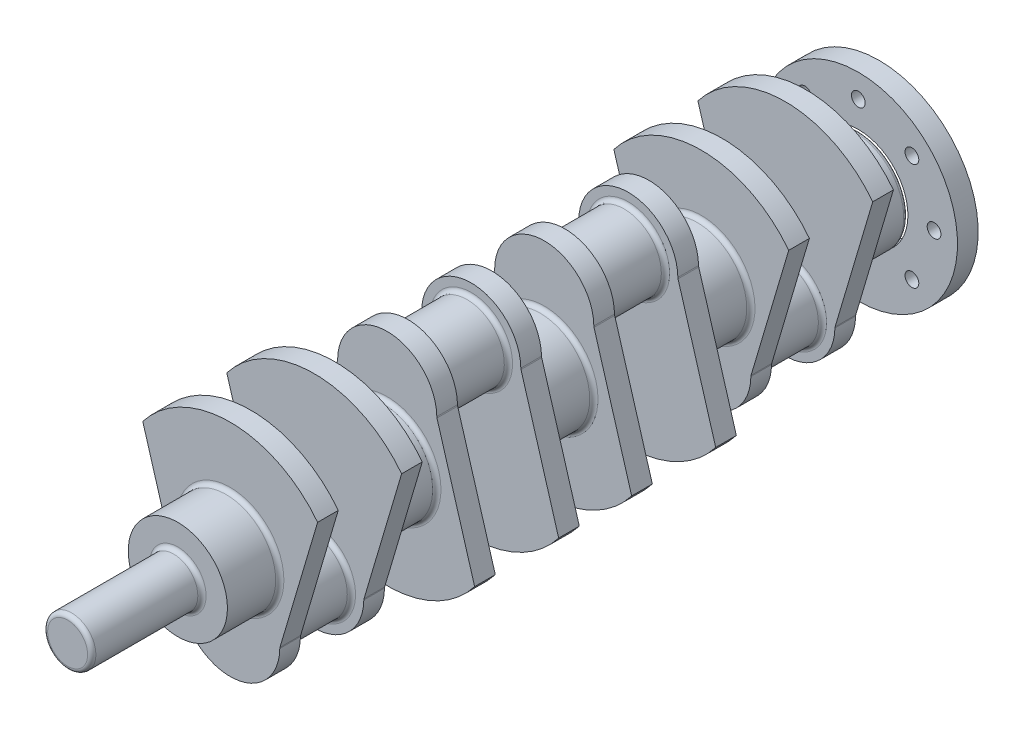
from build123d import *

# Parameters (mm, degrees)
SKETCH1_R             = 36
BOSS_EXTRUDE1_DEPTH   = 15
SKETCH2_R             = 27
BOSS_EXTRUDE2_DEPTH   = 46
SKETCH3_R             = 36
BOSS_EXTRUDE3_DEPTH   = 38
BODY_MOVE_COPY2_ANGLE = 180
SKETCH6_R             = 17.5
BOSS_EXTRUDE5_DEPTH   = 80
SKETCH7_R             = 72
SKETCH7_R_2           = 5
SKETCH7_R_3           = 36
BOSS_EXTRUDE6_DEPTH   = 15
FILLET1_R             = 3
FILLET2_R             = 3


with BuildPart() as part:
    # Sketch1 → Boss-Extrude1 (new body)
    with BuildSketch(Plane.XY):
        with BuildLine():
            ThreePointArc((63.461769721, 48.709380861), (0, 80), (-63.461769721, 48.709380861))
            Line((-63.461769721, 48.709380861), (-36, -44))
            ThreePointArc((-36, -44), (0, -8), (36, -44))
            Line((36, -44), (63.461769721, 48.709380861))
        make_face()
        with Locations((0, -44)):
            Circle(SKETCH1_R)
    boss_extrude1 = extrude(amount=BOSS_EXTRUDE1_DEPTH)

    # Sketch2 → Boss-Extrude2 (add)
    with BuildSketch(Plane(origin=(0, 0, 0), x_dir=(-1, 0, 0), z_dir=(0, 0, -1))):
        with Locations(Location((0, -44, 0), (0, 0, 180))):
            Circle(SKETCH2_R)
    extrude(amount=BOSS_EXTRUDE2_DEPTH)

    # Sketch3 → Boss-Extrude3 (add)
    with BuildSketch(Plane.XY.offset(15)):
        Circle(SKETCH3_R)
    boss_extrude3 = extrude(amount=BOSS_EXTRUDE3_DEPTH)

    # Mirror4: Boss-Extrude1, Boss-Extrude3 across plane
    add(boss_extrude1.mirror(Plane(origin=(0, 0, -23), x_dir=(1, 0, 0), z_dir=(0, 0, -1))))
    add(boss_extrude3.mirror(Plane(origin=(0, 0, -23), x_dir=(1, 0, 0), z_dir=(0, 0, -1))))


with BuildPart() as body_2:
    # Mirror5: mirrored copy
    add(part.part.mirror(Plane(origin=(0, 0, -80), x_dir=(1, 0, 0), z_dir=(0, 0, -1))))


with BuildPart() as body_2_1:
    # Body-Move/Copy2: moved
    add(body_2.part.rotate(Axis((0, 0, -137), (1, 0, 0)), BODY_MOVE_COPY2_ANGLE))


with BuildPart() as body_3:
    # Mirror6: mirrored copy
    add(body_2_1.part.mirror(Plane(origin=(0, 0, -194), x_dir=(1, 0, 0), z_dir=(0, 0, -1))))


with BuildPart() as body_4:
    # Mirror6 2: mirrored copy
    add(part.part.mirror(Plane(origin=(0, 0, -194), x_dir=(1, 0, 0), z_dir=(0, 0, -1))))


with BuildPart() as part_1:
    add(part.part)

    # Sketch6 → Boss-Extrude5 (add)
    with BuildSketch(Plane.XY.offset(53)):
        Circle(SKETCH6_R)
    extrude(amount=BOSS_EXTRUDE5_DEPTH)


with BuildPart() as body_5:
    # Sketch7 → Boss-Extrude6 (new body)
    with BuildSketch(Plane(origin=(0, 0, -441), x_dir=(-1, 0, 0), z_dir=(0, 0, -1))):
        with Locations(Location((0, 0, 0), (0, 0, 90))):
            Circle(SKETCH7_R)
        with Locations(Location((55, 0, 0), (0, 0, 90))):
            Circle(SKETCH7_R_2, mode=Mode.SUBTRACT)
        with Locations(Location((38.890872965, -38.890872965, 0), (0, 0, 90))):
            Circle(SKETCH7_R_2, mode=Mode.SUBTRACT)
        with Locations(Location((0, -55, 0), (0, 0, 90))):
            Circle(SKETCH7_R_2, mode=Mode.SUBTRACT)
        with Locations(Location((-38.890872965, -38.890872965, 0), (0, 0, 90))):
            Circle(SKETCH7_R_2, mode=Mode.SUBTRACT)
        with Locations(Location((-55, 0, 0), (0, 0, 90))):
            Circle(SKETCH7_R_2, mode=Mode.SUBTRACT)
        with Locations(Location((-38.890872965, 38.890872965, 0), (0, 0, 90))):
            Circle(SKETCH7_R_2, mode=Mode.SUBTRACT)
        with Locations(Location((0, 55, 0), (0, 0, 90))):
            Circle(SKETCH7_R_2, mode=Mode.SUBTRACT)
        with Locations(Location((38.890872965, 38.890872965, 0), (0, 0, 90))):
            Circle(SKETCH7_R_2, mode=Mode.SUBTRACT)
        with Locations(Location((0, 0, 0), (0, 0, 90))):
            Circle(SKETCH7_R_3, mode=Mode.SUBTRACT)
    extrude(amount=BOSS_EXTRUDE6_DEPTH)


with BuildPart() as body_4_1:
    add(body_4.part)

    # Combine3: union body 3, body 2, part
    add(body_3.part)
    add(body_2_1.part)
    add(part_1.part)

    # Fillet1
    fillet1_edges = [body_4_1.edges().sort_by_distance(p)[0] for p in [
        (-27, -44, -388),
        (-27, -44, -342),
        (-36, 0, -403),
        (36, -44, -334.5),
        (-36, -44, -334.5),
        (-36, 0, -289),
        (-36, 0, -327),
        (-36, 44, -281.5),
        (36, 44, -281.5),
        (-27, 44, -274),
        (36, 44, -220.5),
        (-36, 44, -220.5),
        (-36, 0, -213),
        (-27, 44, -228),
        (-36, 0, -175),
        (-36, 44, -106.5),
        (36, 44, -106.5),
        (-36, 0, -99),
        (-27, 44, -114),
        (-27, 44, -160),
        (36, 44, -167.5),
        (-36, 44, -167.5),
        (-36, -44, 7.5),
        (36, -44, 7.5),
        (-27, -44, 0),
        (-36, 0, 15),
        (36, -44, -53.5),
        (-36, -44, -53.5),
        (-36, 0, -61),
        (-27, -44, -46),
        (-17.5, 0, 53),
        (-17.5, 0, 133),
        (36, -44, -395.5),
        (-36, -44, -395.5),
    ]]
    fillet(fillet1_edges, radius=FILLET1_R)

    # Fillet2
    fillet2_edges = [body_4_1.edges().sort_by_distance(p)[0] for p in [
        (-36, 0, -441),
    ]]
    fillet(fillet2_edges, radius=FILLET2_R)


solid = Compound([body_5.part, body_4_1.part])
